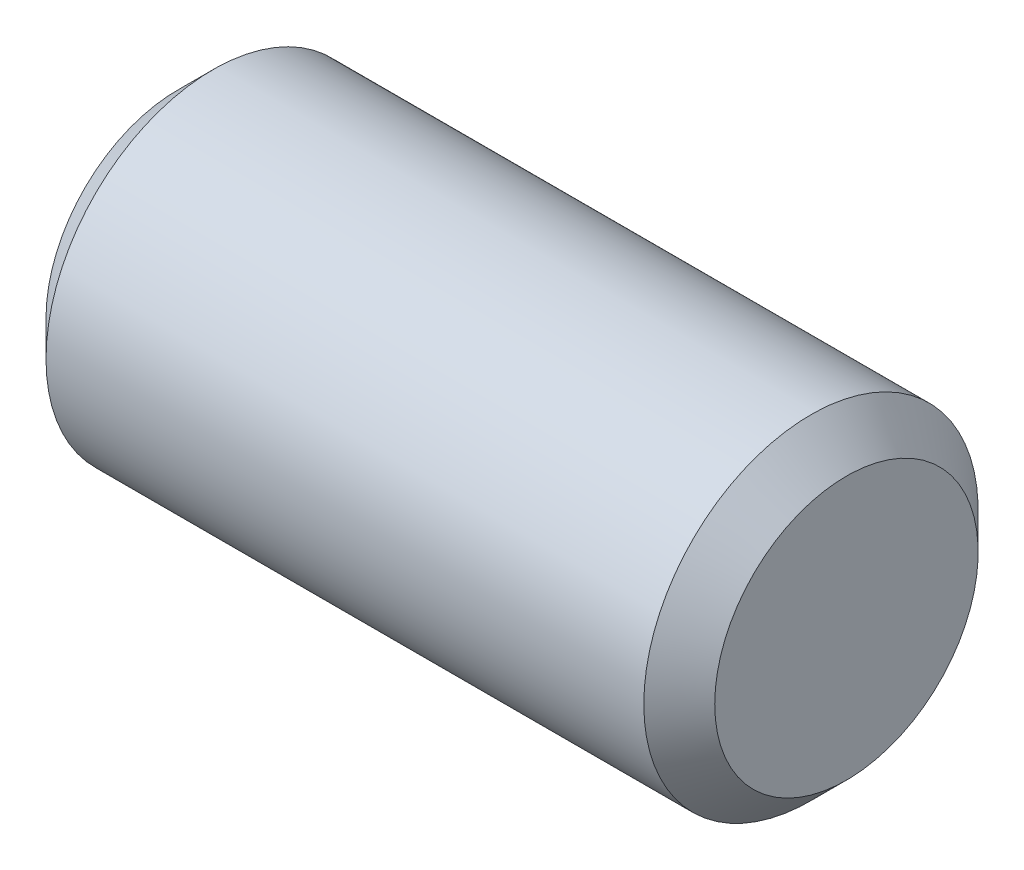
from build123d import *


with BuildPart() as part:
    # Sketch1 → Revolve1 (revolve)
    with BuildSketch(Plane.XY):
        Polygon((-1.806613277, 0), (-1.806613277, -0.787867966), (-1.594481243, -1), (1.981254688, -1), (2.193386723, -0.787867966), (2.193386723, 0), align=None)
    revolve(axis=Axis((-3.007407407, 0, 0), (1, 0, 0)))


solid = part.part
